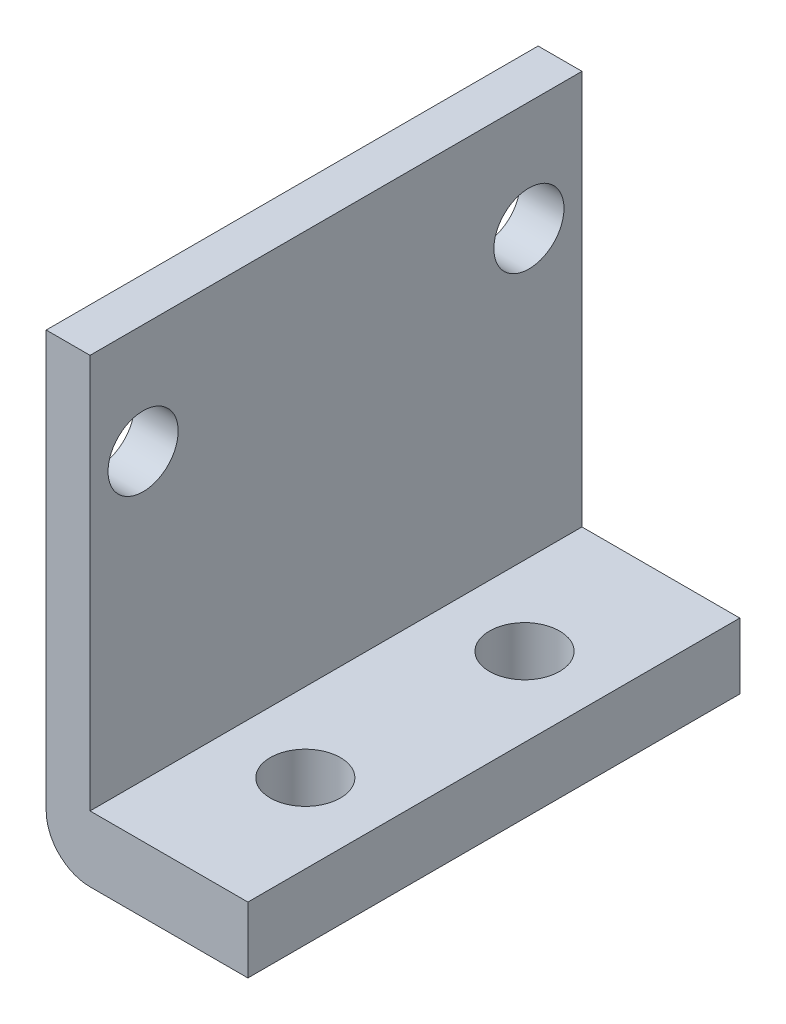
from build123d import *

# Parameters (mm, degrees)
SKETCH2_W           = 9.2
SKETCH2_H           = 22.44
SKETCH2_R           = 1.6
BOSS_EXTRUDE2_DEPTH = 3
SKETCH4_W           = 2
SKETCH4_H           = 22.44
BOSS_EXTRUDE3_DEPTH = 18
FILLET1_R           = 2
SKETCH5_R           = 1.6
CUT_EXTRUDE1_DEPTH  = 18


with BuildPart() as part:
    # Sketch2 → Boss-Extrude2 (new body)
    with BuildSketch(Plane(origin=(0, 0, 0), x_dir=(1, 0, 0), z_dir=(0, 1, 0))):
        with Locations((4.6, 11.22)):
            Rectangle(SKETCH2_W, SKETCH2_H)
        with Locations((5.6, 16.22)):
            Circle(SKETCH2_R, mode=Mode.SUBTRACT)
        with Locations((5.6, 6.22)):
            Circle(SKETCH2_R, mode=Mode.SUBTRACT)
    extrude(amount=BOSS_EXTRUDE2_DEPTH)

    # Sketch4 → Boss-Extrude3 (add)
    with BuildSketch(Plane(origin=(0, 3, 0), x_dir=(1, 0, 0), z_dir=(0, 1, 0))):
        with Locations((1, 11.22)):
            Rectangle(SKETCH4_W, SKETCH4_H)
    extrude(amount=BOSS_EXTRUDE3_DEPTH)

    # Fillet1
    fillet1_edges = [part.edges().sort_by_distance(p)[0] for p in [
        (0, 0, -11.22),
    ]]
    fillet(fillet1_edges, radius=FILLET1_R)

    # Sketch5 → Cut-Extrude1 (cut)
    with BuildSketch(Plane(origin=(2, 0, 0), x_dir=(0, 0, -1), z_dir=(1, 0, 0))):
        with Locations((2.42, 16)):
            Circle(SKETCH5_R)
        with Locations((20.02, 16)):
            Circle(SKETCH5_R)
    extrude(amount=-CUT_EXTRUDE1_DEPTH, mode=Mode.SUBTRACT)


solid = part.part
